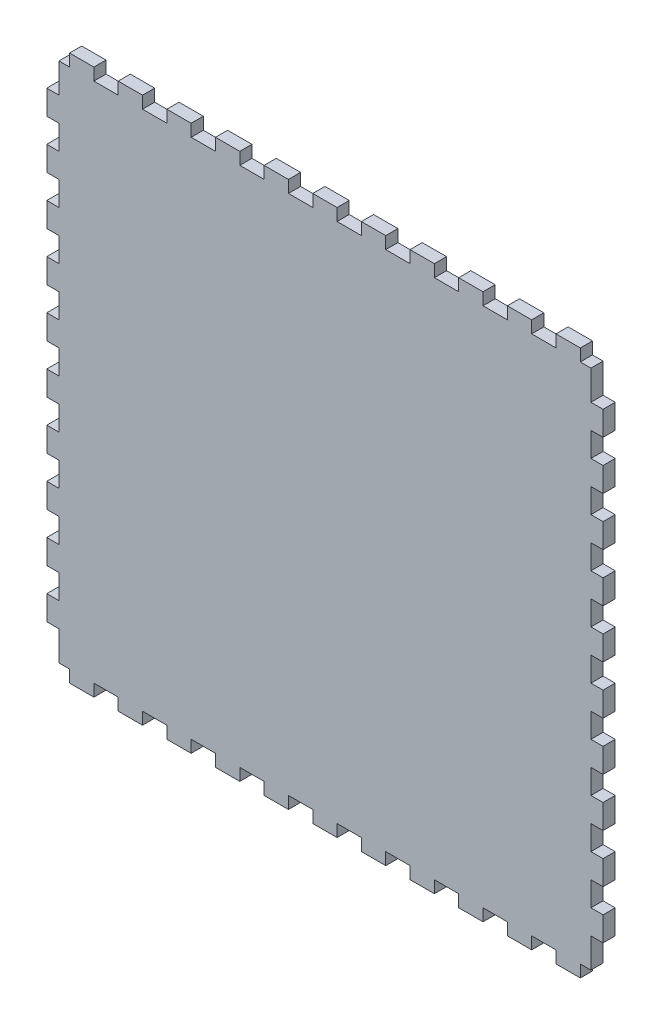
from build123d import *

# Parameters (mm, degrees)
BOSS_EXTRUDE1_DEPTH = 5.715


with BuildPart() as part:
    # Model → Boss-Extrude1 (new body)
    with BuildSketch(Plane.XY):
        Polygon((544.68776, 28.91536), (549.67378, 28.91536), (549.67378, 23.2006394), (561.10632, 23.2006394), (561.10632, 28.91536), (572.53378, 28.91536), (572.53378, 23.2006394), (583.96378, 23.2006394), (583.96378, 28.91536), (595.39378, 28.91536), (595.39378, 23.2006394), (606.82378, 23.2006394), (606.82378, 28.91536), (618.25632, 28.91536), (618.25632, 23.2006394), (629.68378, 23.2006394), (629.68378, 28.91536), (641.11378, 28.91536), (641.11378, 23.2006394), (652.54378, 23.2006394), (652.54378, 28.91536), (663.97378, 28.91536), (663.97378, 23.2006394), (675.40632, 23.2006394), (675.40632, 28.91536), (686.83378, 28.91536), (686.83378, 23.2006394), (698.26378, 23.2006394), (698.26378, 28.91536), (709.69378, 28.91536), (709.69378, 23.2006394), (721.12378, 23.2006394), (721.12378, 28.91536), (732.55632, 28.91536), (732.55632, 23.2006394), (743.98378, 23.2006394), (743.98378, 28.91536), (755.41378, 28.91536), (755.41378, 23.2006394), (766.84378, 23.2006394), (766.84378, 28.91536), (778.27378, 28.91536), (778.27378, 23.2006394), (789.70632, 23.2006394), (789.70632, 28.91536), (794.68726, 28.91536), (794.68726, 42.83075), (800.40226, 42.83075), (800.40226, 54.260496), (794.68726, 54.260496), (794.68726, 65.691004), (800.40226, 65.691004), (800.40226, 77.120496), (794.68726, 77.120496), (794.68726, 88.549988), (800.40226, 88.549988), (800.40226, 99.98075), (794.68726, 99.98075), (794.68726, 111.410496), (800.40226, 111.410496), (800.40226, 122.841004), (794.68726, 122.841004), (794.68726, 134.270496), (800.40226, 134.270496), (800.40226, 145.699988), (794.68726, 145.699988), (794.68726, 157.13075), (800.40226, 157.13075), (800.40226, 168.560496), (794.68726, 168.560496), (794.68726, 179.991004), (800.40226, 179.991004), (800.40226, 191.420496), (794.68726, 191.420496), (794.68726, 202.849988), (800.40226, 202.849988), (800.40226, 214.28075), (794.68726, 214.28075), (794.68726, 225.710496), (800.40226, 225.710496), (800.40226, 237.141004), (794.68726, 237.141004), (794.68726, 248.570496), (800.40226, 248.570496), (800.40226, 259.99948), (794.68726, 259.99948), (794.68726, 273.91614), (789.70632, 273.91614), (789.70632, 279.63114), (778.27378, 279.63114), (778.27378, 273.91614), (766.84378, 273.91614), (766.84378, 279.63114), (755.41378, 279.63114), (755.41378, 273.91614), (743.98378, 273.91614), (743.98378, 279.63114), (732.55632, 279.63114), (732.55632, 273.91614), (721.12378, 273.91614), (721.12378, 279.63114), (709.69378, 279.63114), (709.69378, 273.91614), (698.26378, 273.91614), (698.26378, 279.63114), (686.83378, 279.63114), (686.83378, 273.91614), (675.40632, 273.91614), (675.40632, 279.63114), (663.97378, 279.63114), (663.97378, 273.91614), (652.54378, 273.91614), (652.54378, 279.63114), (641.11378, 279.63114), (641.11378, 273.91614), (629.68378, 273.91614), (629.68378, 279.63114), (618.25632, 279.63114), (618.25632, 273.91614), (606.82378, 273.91614), (606.82378, 279.63114), (595.39378, 279.63114), (595.39378, 273.91614), (583.96378, 273.91614), (583.96378, 279.63114), (572.53378, 279.63114), (572.53378, 273.91614), (561.10632, 273.91614), (561.10632, 279.63114), (549.67378, 279.63114), (549.67378, 273.91614), (544.68776, 273.91614), (544.68776, 259.99948), (538.97276, 259.99948), (538.97276, 248.570496), (544.68776, 248.570496), (544.68776, 237.141004), (538.97276, 237.141004), (538.97276, 225.710496), (544.68776, 225.710496), (544.68776, 214.28075), (538.97276, 214.28075), (538.97276, 202.849988), (544.68776, 202.849988), (544.68776, 191.420496), (538.97276, 191.420496), (538.97276, 179.991004), (544.68776, 179.991004), (544.68776, 168.560496), (538.97276, 168.560496), (538.97276, 157.13075), (544.68776, 157.13075), (544.68776, 145.699988), (538.97276, 145.699988), (538.97276, 134.270496), (544.68776, 134.270496), (544.68776, 122.841004), (538.97276, 122.841004), (538.97276, 111.410496), (544.68776, 111.410496), (544.68776, 99.98075), (538.97276, 99.98075), (538.97276, 88.549988), (544.68776, 88.549988), (544.68776, 77.120496), (538.97276, 77.120496), (538.97276, 65.691004), (544.68776, 65.691004), (544.68776, 54.260496), (538.97276, 54.260496), (538.97276, 42.83075), (544.68776, 42.83075), align=None)
    extrude(amount=BOSS_EXTRUDE1_DEPTH)


solid = part.part
